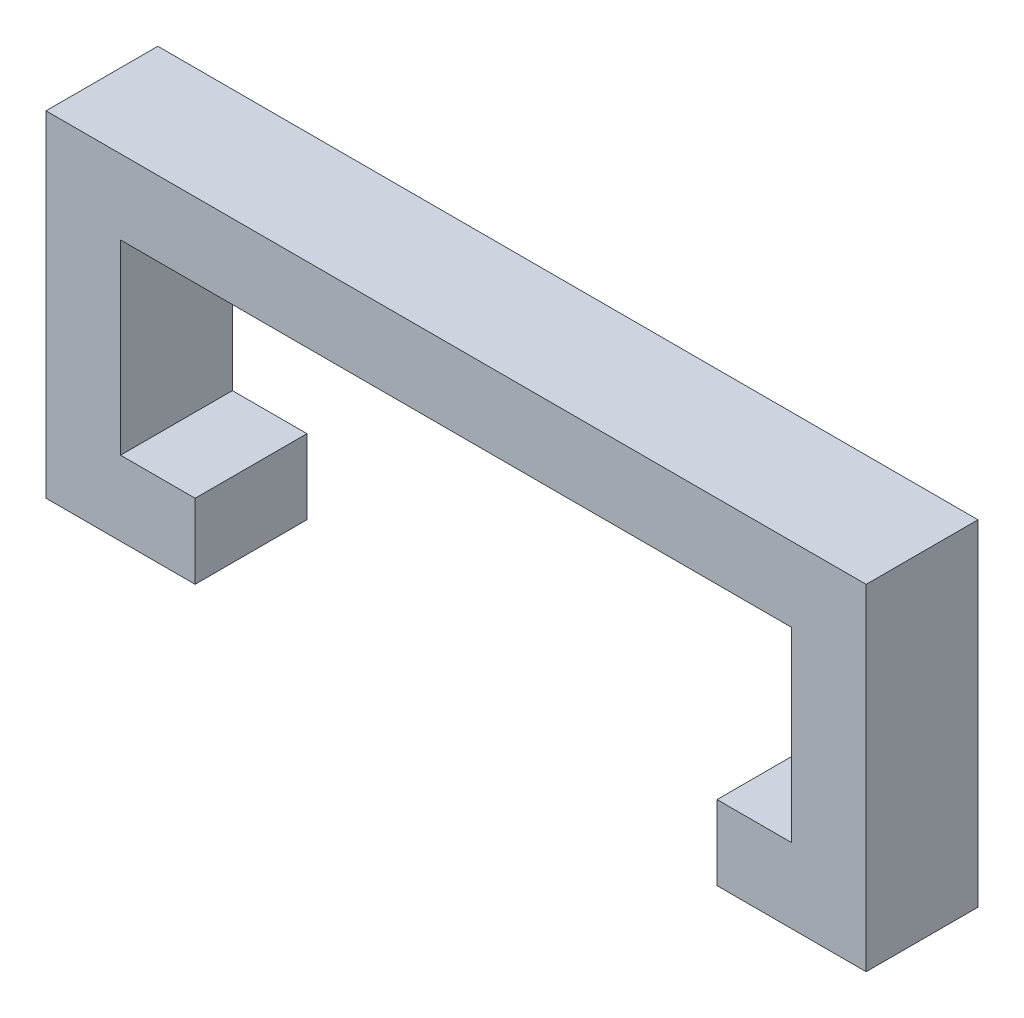
from build123d import *

# Parameters (mm, degrees)
BOSS_EXTRUDE1_DEPTH = 7.62


with BuildPart() as part:
    # Sketch1 → Boss-Extrude1 (new body)
    with BuildSketch(Plane.XY):
        Polygon((12.933730498, -5.378742175), (12.933730498, -10.458742175), (23.093730498, -10.458742175), (23.093730498, 12.401257825), (-32.786269502, 12.401257825), (-32.786269502, -10.458742175), (-22.626269502, -10.458742175), (-22.626269502, -5.378742175), (-27.706269502, -5.378742175), (-27.706269502, 7.321257825), (18.013730498, 7.321257825), (18.013730498, -5.378742175), align=None)
    extrude(amount=BOSS_EXTRUDE1_DEPTH)


solid = part.part
